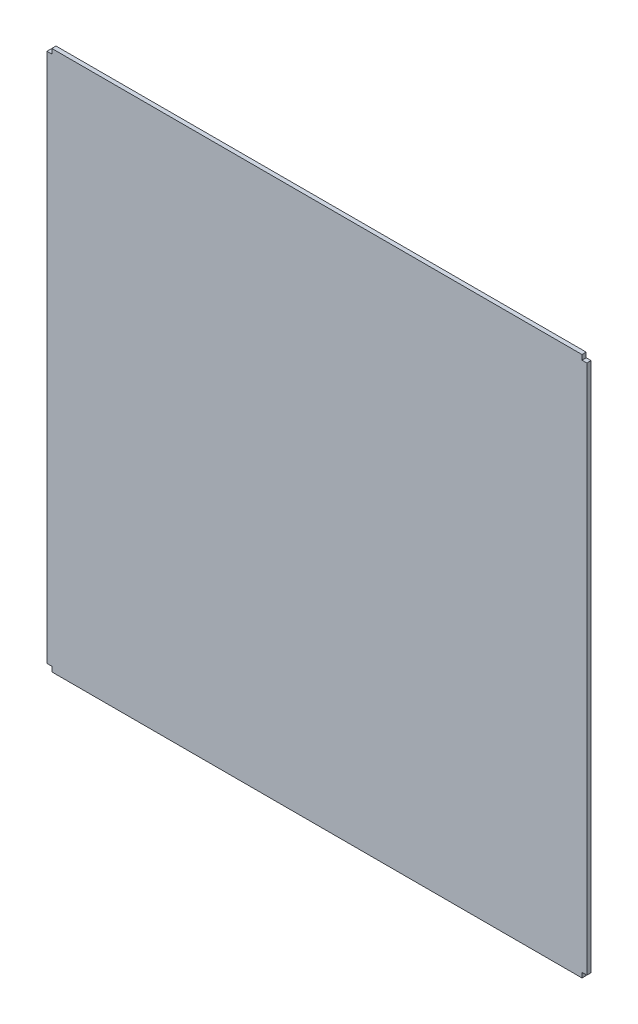
from build123d import *

# Parameters (mm, degrees)
SKETCH1_W           = 579
SKETCH1_H           = 579
BOSS_EXTRUDE1_DEPTH = 2.2479
CUT_EXTRUDE1_DEPTH  = 4.4958


with BuildPart() as part:
    # Sketch1 → Boss-Extrude1 (new body, symmetric)
    with BuildSketch(Plane.XY):
        Rectangle(SKETCH1_W, SKETCH1_H)
    extrude(amount=BOSS_EXTRUDE1_DEPTH, both=True)

    # Sketch2 → Cut-Extrude1 (cut)
    with BuildSketch(Plane.XY.offset(2.2479)):
        Polygon((-284.25, 303.749993563), (-284.25, 284.249993563), (-303.75, 284.249993563), align=None)
        Polygon((-303.75, -284.250006437), (-284.25, -284.250006437), (-284.25, -303.750006437), align=None)
        Polygon((284.25, -303.750006437), (284.25, -284.250006437), (303.75, -284.250006437), align=None)
        Polygon((303.75, 284.249993563), (284.25, 284.249993563), (284.25, 303.749993563), align=None)
    extrude(amount=-CUT_EXTRUDE1_DEPTH, mode=Mode.SUBTRACT)


solid = part.part
